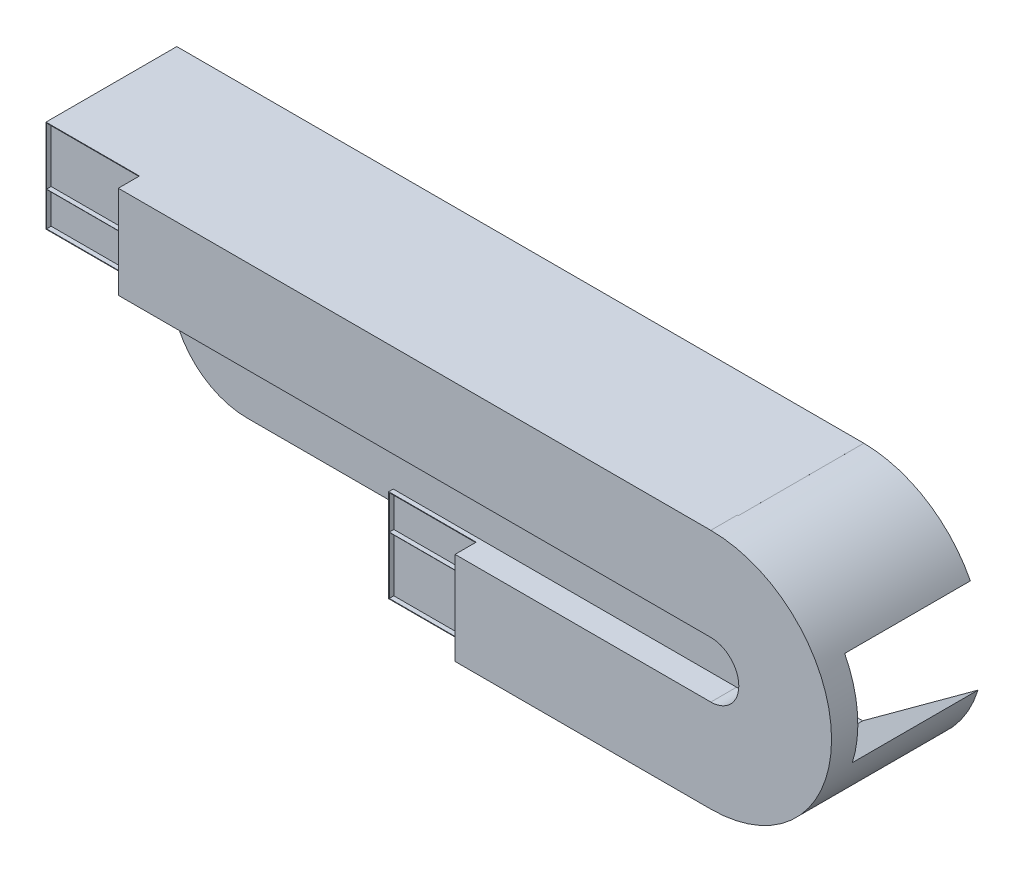
from build123d import *

# Parameters (mm, degrees)
ESTRUSIONE_ESTRUSIONE1_START      = 1100
ESTRUSIONE_ESTRUSIONE1_DEPTH      = 5
ESTRUSIONE_ESTRUSIONE2_DEPTH      = 40
ESTRUSIONE_ESTRUSIONE2_DEPTH_BACK = 5
ESTRUSIONE_ESTRUSIONE3_DEPTH      = 40
ESTRUSIONE_ESTRUSIONE4_DEPTH      = 180
ESTRUSIONE_ESTRUSIONE5_DEPTH      = 5
ESTRUSIONE_ESTRUSIONE10_DEPTH     = 1100
ESTRUSIONE_ESTRUSIONE11_DEPTH     = 1100
ESTRUSIONE_ESTRUSIONE12_DEPTH     = 1100
SCHIZZO17_W                       = 1100
SCHIZZO17_H                       = 43.876411271
ESTRUSIONE_ESTRUSIONE13_DEPTH     = 2559
ESTRUSIONE_ESTRUSIONE14_DEPTH     = 5
SCHIZZO19_W                       = 5
SCHIZZO19_H                       = 490.0043726
ESTRUSIONE_ESTRUSIONE15_DEPTH     = 3500
TAGLIO_ESTRUSIONE1_DEPTH          = 3500


with BuildPart() as part:
    # Schizzo1 → Estrusione-Estrusione1 (new body)
    with BuildSketch(Plane.XY.offset(ESTRUSIONE_ESTRUSIONE1_START)):
        with BuildLine():
            Line((-7028, 842), (-7028, 1344))
            Line((-7028, 1344), (-1028, 1344))
            ThreePointArc((-1028, 1344), (24, 292), (-1028, -760))
            Line((-1028, -760), (-4028, -760))
            Line((-4028, -760), (-4028, 42))
            Line((-4028, 42), (-1028, 42))
            ThreePointArc((-1028, 42), (-778, 292), (-1028, 542))
            Line((-1028, 542), (-7028, 542))
            Line((-7028, 542), (-7028, 842))
        make_face()
    extrude(amount=ESTRUSIONE_ESTRUSIONE1_DEPTH)

    # Schizzo2 → Estrusione-Estrusione2 (add, two sides)
    with BuildSketch(Plane.XY.offset(1105)) as estrusione_estrusione2_sk:
        with BuildLine():
            Line((-1028, 1349), (-7033, 1349))
            Line((-7033, 1349), (-7033, 537))
            Line((-7033, 537), (-1028, 537))
            ThreePointArc((-1028, 537), (-783, 292), (-1028, 47))
            Line((-1028, 47), (-4033, 47))
            Line((-4033, 47), (-4033, -765))
            Line((-4033, -765), (-1028, -765))
            ThreePointArc((-1028, -765), (29, 292), (-1028, 1349))
        make_face()
        with BuildLine():
            Line((-1028, 1344), (-7028, 1344))
            Line((-7028, 1344), (-7028, 542))
            Line((-7028, 542), (-1028, 542))
            ThreePointArc((-1028, 542), (-778, 292), (-1028, 42))
            Line((-1028, 42), (-4028, 42))
            Line((-4028, 42), (-4028, -760))
            Line((-4028, -760), (-1028, -760))
            ThreePointArc((-1028, -760), (24, 292), (-1028, 1344))
        make_face(mode=Mode.SUBTRACT)
    extrude(amount=ESTRUSIONE_ESTRUSIONE2_DEPTH)
    extrude(estrusione_estrusione2_sk.sketch, amount=-ESTRUSIONE_ESTRUSIONE2_DEPTH_BACK)

    # Schizzo3 → Estrusione-Estrusione3 (add)
    with BuildSketch(Plane.XY.offset(1105)):
        with BuildLine():
            Line((-4028, -259), (-1028, -259))
            ThreePointArc((-1028, -259), (-477, 292), (-1028, 843))
            Line((-1028, 843), (-7028, 843))
            Line((-7028, 843), (-7028, 841))
            Line((-7028, 841), (-1028, 841))
            ThreePointArc((-1028, 841), (-479, 292), (-1028, -257))
            Line((-1028, -257), (-4028, -257))
            Line((-4028, -257), (-4028, -259))
        make_face()
    extrude(amount=ESTRUSIONE_ESTRUSIONE3_DEPTH)

    # Schizzo4 → Estrusione-Estrusione4 (add)
    with BuildSketch(Plane.XY.offset(1145)):
        with BuildLine():
            Line((-1028, 1344), (-6214.994472708, 1344))
            Line((-6214.994472708, 1344), (-6214.994472708, 1349))
            Line((-6214.994472708, 1349), (-1028, 1349))
            ThreePointArc((-1028, 1349), (29, 292), (-1028, -765))
            Line((-1028, -765), (-3267.096775187, -765))
            Line((-3267.096775187, -765), (-3267.096775187, -760))
            Line((-3267.096775187, -760), (-1028, -760))
            ThreePointArc((-1028, -760), (24, 292), (-1028, 1344))
        make_face()
        with BuildLine():
            Line((-6214.994472708, 542), (-1028, 542))
            ThreePointArc((-1028, 542), (-778, 292), (-1028, 42))
            Line((-1028, 42), (-3267.096775187, 42))
            Line((-3267.096775187, 42), (-3267.096775187, 47))
            Line((-3267.096775187, 47), (-1028, 47))
            ThreePointArc((-1028, 47), (-783, 292), (-1028, 537))
            Line((-1028, 537), (-6214.994472708, 537))
            Line((-6214.994472708, 537), (-6214.994472708, 542))
        make_face()
    extrude(amount=ESTRUSIONE_ESTRUSIONE4_DEPTH)

    # Schizzo7 → Estrusione-Estrusione5 (add)
    with BuildSketch(Plane.XY.offset(1325)):
        with BuildLine():
            Line((-3267.096775187, 42), (-3267.096775187, -760))
            Line((-3267.096775187, -760), (-3267.096775187, -765))
            Line((-3267.096775187, -765), (-1028, -765))
            ThreePointArc((-1028, -765), (29, 292), (-1028, 1349))
            Line((-1028, 1349), (-6214.994472708, 1349))
            Line((-6214.994472708, 1349), (-6214.994472708, 1344))
            Line((-6214.994472708, 1344), (-6214.994472708, 542))
            Line((-6214.994472708, 542), (-6214.994472708, 537))
            Line((-6214.994472708, 537), (-1028, 537))
            ThreePointArc((-1028, 537), (-783, 292), (-1028, 47))
            Line((-1028, 47), (-3267.096775187, 47))
            Line((-3267.096775187, 47), (-3267.096775187, 42))
        make_face()
    extrude(amount=ESTRUSIONE_ESTRUSIONE5_DEPTH)

    # Schizzo14 → Estrusione-Estrusione10 (add)
    with BuildSketch(Plane(origin=(0, 0, 1100), x_dir=(-1, 0, 0), z_dir=(0, 0, -1))):
        Polygon((7033, 1344), (7033, 1349), (7028, 1349), (1018.37897453, 1349), (1018.37897453, 1344), (7028, 1344), (7028, 814.840458961), (7033, 814.840458961), align=None)
    extrude(amount=ESTRUSIONE_ESTRUSIONE10_DEPTH)

    # Schizzo15 → Estrusione-Estrusione11 (add)
    with BuildSketch(Plane(origin=(0, 0, 1100), x_dir=(-1, 0, 0), z_dir=(0, 0, -1))):
        with BuildLine():
            Line((1018.37897453, 1348.956212844), (1018.37897453, 1344))
            Line((1018.37897453, 1344), (86.000959701, 771.465127069))
            ThreePointArc((86.000959701, 771.465127069), (471.430888451, 1190.598811522), (1018.37897453, 1348.956212844))
        make_face()
    extrude(amount=ESTRUSIONE_ESTRUSIONE11_DEPTH)

    # Schizzo16 → Estrusione-Estrusione12 (add)
    with BuildSketch(Plane(origin=(0, 0, 1100), x_dir=(-1, 0, 0), z_dir=(0, 0, -1))):
        with BuildLine():
            Line((1028, -760), (19.038362428, -23.032401362))
            ThreePointArc((19.038362428, -23.032401362), (401.797256569, -559.539267515), (1028, -765))
            Line((1028, -765), (4001.270866126, -765))
            Line((4001.270866126, -765), (4033, -765))
            Line((4033, -765), (4033, -760))
            Line((4033, -760), (4033, -10.892573997))
            Line((4033, -10.892573997), (4001.270866126, -10.892573997))
            Line((4001.270866126, -10.892573997), (4001.270866126, -760))
            Line((4001.270866126, -760), (1028, -760))
        make_face()
    extrude(amount=ESTRUSIONE_ESTRUSIONE12_DEPTH)

    # Schizzo17 → Estrusione-Estrusione13 (add)
    with BuildSketch(Plane.ZY.offset(4033)):
        with Locations((550, -32.830779633)):
            Rectangle(SCHIZZO17_W, SCHIZZO17_H)
    extrude(amount=ESTRUSIONE_ESTRUSIONE13_DEPTH)

    # Schizzo18 → Estrusione-Estrusione14 (add)
    with BuildSketch(Plane.XY.offset(1100)):
        with BuildLine():
            Line((-6147.55950035, 537), (-4030.5, 537))
            Line((-4030.5, 537), (-4033, -54.768985268))
            Line((-4033, -54.768985268), (-5312.5, -54.768985268))
            ThreePointArc((-5312.5, -54.768985268), (-5695.617990734, 67.217730963), (-5937.672489152, 388.262546459))
            ThreePointArc((-5937.672489152, 388.262546459), (-6018.936614016, 496.045819002), (-6147.55950035, 537))
        make_face()
    extrude(amount=ESTRUSIONE_ESTRUSIONE14_DEPTH)

    # Schizzo19 → Estrusione-Estrusione15 (add)
    with BuildSketch(Plane(origin=(-4032.696648506, 17.036617113, 0), x_dir=(0, 0, -1), z_dir=(0.999991076, -0.004224584, 0))):
        with Locations((-1102.5, 274.965836571)):
            Rectangle(SCHIZZO19_W, SCHIZZO19_H)
    extrude(amount=ESTRUSIONE_ESTRUSIONE15_DEPTH)

    # Schizzo20 → Taglio-Estrusione1 (cut)
    with BuildSketch(Plane.XY.offset(1100)):
        with BuildLine():
            Line((-5312.5, -54.768985268), (-5312.5, -181.34183241))
            Line((-5312.5, -181.34183241), (-6649.482610295, -181.34183241))
            Line((-6649.482610295, -181.34183241), (-6649.482610295, 67.217730963))
            Line((-6649.482610295, 67.217730963), (-5695.617990734, 67.217730963))
            ThreePointArc((-5695.617990734, 67.217730963), (-5513.53491846, -23.536216894), (-5312.5, -54.768985268))
        make_face()
    extrude(amount=-TAGLIO_ESTRUSIONE1_DEPTH, mode=Mode.SUBTRACT)


solid = part.part
